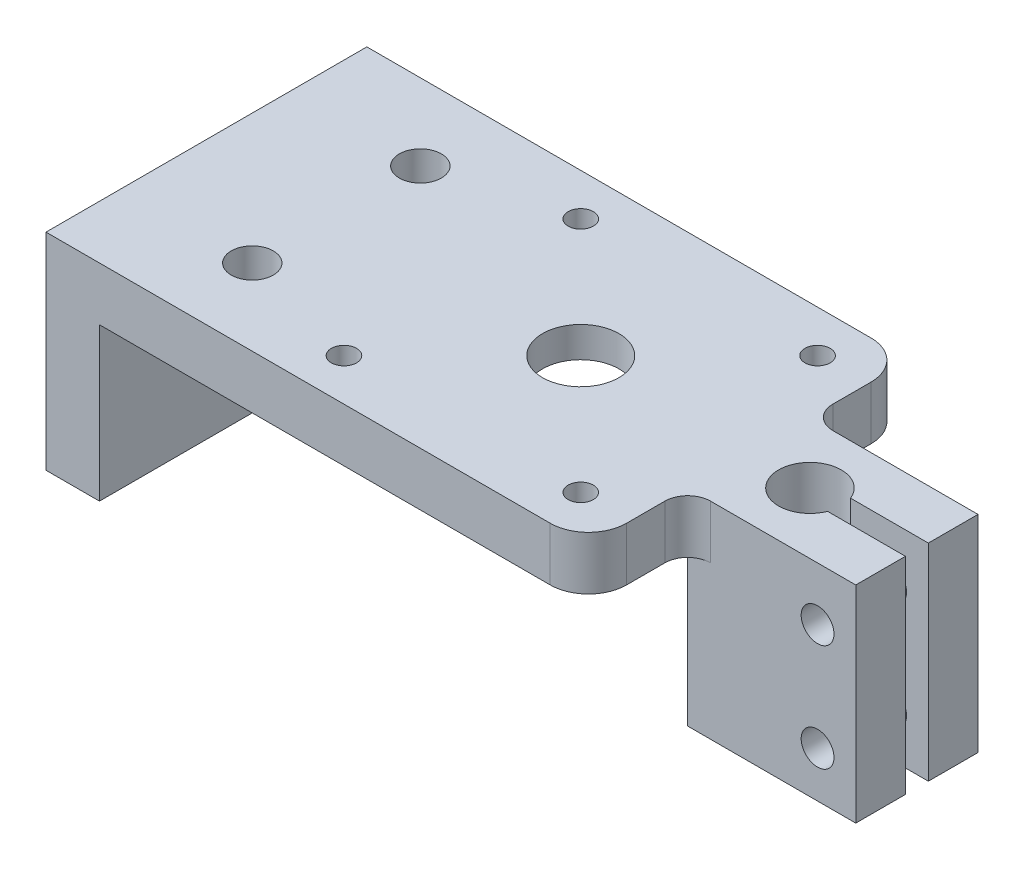
from build123d import *

# Parameters (mm, degrees)
SKETCH1_W                = 64
SKETCH1_H                = 42
BOSS_EXTRUDE1_DEPTH      = 7
SKETCH11_W               = 22
SKETCH11_H               = 16
BOSS_EXTRUDE3_DEPTH      = 7
BOSS_EXTRUDE3_DEPTH_BACK = 20
SKETCH3_R                = 12
CUT_EXTRUDE2_DEPTH       = 3
SKETCH2_R                = 4.1
CUT_EXTRUDE1_DEPTH       = 28
SKETCH4_R                = 2.75
CUT_EXTRUDE3_DEPTH       = 28
SKETCH7_R                = 1.65
CUT_EXTRUDE5_DEPTH       = 28
SKETCH8_W                = 42
SKETCH8_H                = 27
BOSS_EXTRUDE2_DEPTH      = 7
SKETCH9_R                = 2.7
CUT_EXTRUDE6_DEPTH       = 1
CUT_EXTRUDE6_DEPTH_BACK  = 13
SKETCH10_R               = 5
CUT_EXTRUDE7_DEPTH       = 20
SKETCH15_R               = 2.15
CUT_EXTRUDE8_DEPTH       = 22
SKETCH16_W               = 14
SKETCH16_H               = 3
CUT_EXTRUDE9_DEPTH       = 28
FILLET1_R                = 3
FILLET2_R                = 5


with BuildPart() as part:
    # Sketch1 → Boss-Extrude1 (new body)
    with BuildSketch(Plane(origin=(0, 0, 0), x_dir=(1, 0, 0), z_dir=(0, 1, 0))):
        Rectangle(SKETCH1_W, SKETCH1_H)
    extrude(amount=BOSS_EXTRUDE1_DEPTH)

    # Sketch11 → Boss-Extrude3 (add, two sides)
    with BuildSketch(Plane(origin=(0, 0, 0), x_dir=(1, 0, 0), z_dir=(0, 1, 0))) as boss_extrude3_sk:
        with Locations((43, 0)):
            Rectangle(SKETCH11_W, SKETCH11_H)
    extrude(amount=BOSS_EXTRUDE3_DEPTH)
    extrude(boss_extrude3_sk.sketch, amount=-BOSS_EXTRUDE3_DEPTH_BACK)

    # Sketch3 → Cut-Extrude2 (cut)
    with BuildSketch(Plane(origin=(0, 0, 0), x_dir=(1, 0, 0), z_dir=(0, 1, 0))):
        with Locations((10, 0)):
            Circle(SKETCH3_R)
    extrude(amount=CUT_EXTRUDE2_DEPTH, mode=Mode.SUBTRACT)

    # Sketch2 → Cut-Extrude1 (cut, through all)
    with BuildSketch(Plane(origin=(0, 7, 0), x_dir=(1, 0, 0), z_dir=(0, 1, 0))):
        with Locations((40, 0)):
            Circle(SKETCH2_R)
    extrude(amount=-CUT_EXTRUDE1_DEPTH, mode=Mode.SUBTRACT)

    # Sketch4 → Cut-Extrude3 (cut, through all)
    with BuildSketch(Plane(origin=(0, 7, 0), x_dir=(1, 0, 0), z_dir=(0, 1, 0))):
        with Locations((-22, 11)):
            Circle(SKETCH4_R)
        with Locations((-22, -11)):
            Circle(SKETCH4_R)
    extrude(amount=-CUT_EXTRUDE3_DEPTH, mode=Mode.SUBTRACT)

    # Sketch7 → Cut-Extrude5 (cut, through all)
    with BuildSketch(Plane(origin=(0, 7, 0), x_dir=(1, 0, 0), z_dir=(0, 1, 0))):
        with Locations((-5.5, 15.5)):
            Circle(SKETCH7_R)
        with Locations((25.5, 15.5)):
            Circle(SKETCH7_R)
        with Locations((25.5, -15.5)):
            Circle(SKETCH7_R)
        with Locations((-5.5, -15.5)):
            Circle(SKETCH7_R)
    extrude(amount=-CUT_EXTRUDE5_DEPTH, mode=Mode.SUBTRACT)

    # Sketch8 → Boss-Extrude2 (add)
    with BuildSketch(Plane.ZY.offset(32)):
        with Locations((0, -6.5)):
            Rectangle(SKETCH8_W, SKETCH8_H)
    extrude(amount=BOSS_EXTRUDE2_DEPTH)

    # Sketch9 → Cut-Extrude6 (cut, two sides)
    with BuildSketch(Plane.ZY.offset(39)) as cut_extrude6_sk:
        with Locations((0, -10)):
            Circle(SKETCH9_R)
    extrude(amount=CUT_EXTRUDE6_DEPTH, mode=Mode.SUBTRACT)
    extrude(cut_extrude6_sk.sketch, amount=-CUT_EXTRUDE6_DEPTH_BACK, mode=Mode.SUBTRACT)

    # Sketch10 → Cut-Extrude7 (cut)
    with BuildSketch(Plane(origin=(0, 7, 0), x_dir=(1, 0, 0), z_dir=(0, 1, 0))):
        with Locations((10, 0)):
            Circle(SKETCH10_R)
    extrude(amount=-CUT_EXTRUDE7_DEPTH, mode=Mode.SUBTRACT)

    # Sketch15 → Cut-Extrude8 (cut)
    with BuildSketch(Plane(origin=(0, 0, -8), x_dir=(-1, 0, 0), z_dir=(0, 0, -1))):
        with Locations((-49, 0)):
            Circle(SKETCH15_R)
        with Locations((-49, -14)):
            Circle(SKETCH15_R)
    extrude(amount=-CUT_EXTRUDE8_DEPTH, mode=Mode.SUBTRACT)

    # Sketch16 → Cut-Extrude9 (cut, through all)
    with BuildSketch(Plane(origin=(0, 7, 0), x_dir=(1, 0, 0), z_dir=(0, 1, 0))):
        with Locations((47, 0)):
            Rectangle(SKETCH16_W, SKETCH16_H)
    extrude(amount=-CUT_EXTRUDE9_DEPTH, mode=Mode.SUBTRACT)

    # Fillet1
    fillet1_edges = [part.edges().sort_by_distance(p)[0] for p in [
        (32, 3.5, -8),
        (32, 3.5, 8),
    ]]
    fillet(fillet1_edges, radius=FILLET1_R)

    # Fillet2
    fillet2_edges = [part.edges().sort_by_distance(p)[0] for p in [
        (32, 3.5, 21),
        (32, 3.5, -21),
    ]]
    fillet(fillet2_edges, radius=FILLET2_R)


solid = part.part
